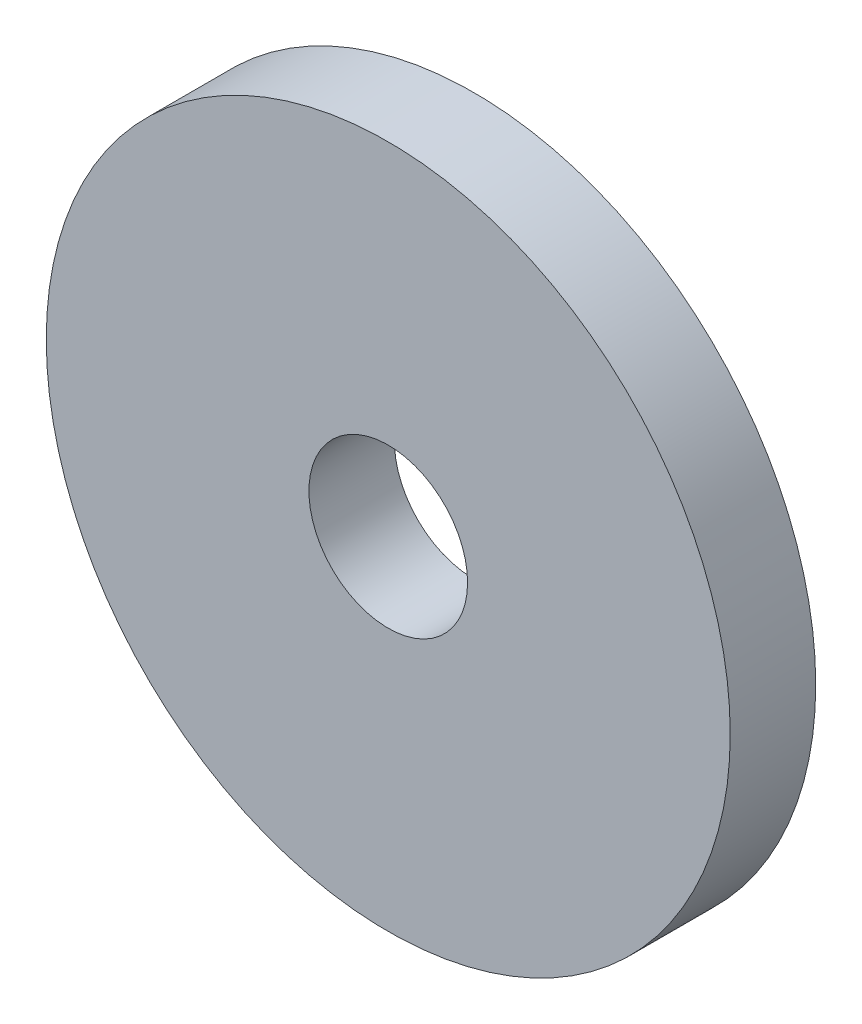
from build123d import *

# Parameters (mm, degrees)
SKETCH1_R           = 6.35
SKETCH1_R_2         = 1.4732
BOSS_EXTRUDE1_DEPTH = 1.5875


with BuildPart() as part:
    # Sketch1 → Boss-Extrude1 (new body)
    with BuildSketch(Plane.XY):
        Circle(SKETCH1_R)
        Circle(SKETCH1_R_2, mode=Mode.SUBTRACT)
    extrude(amount=BOSS_EXTRUDE1_DEPTH)


solid = part.part
